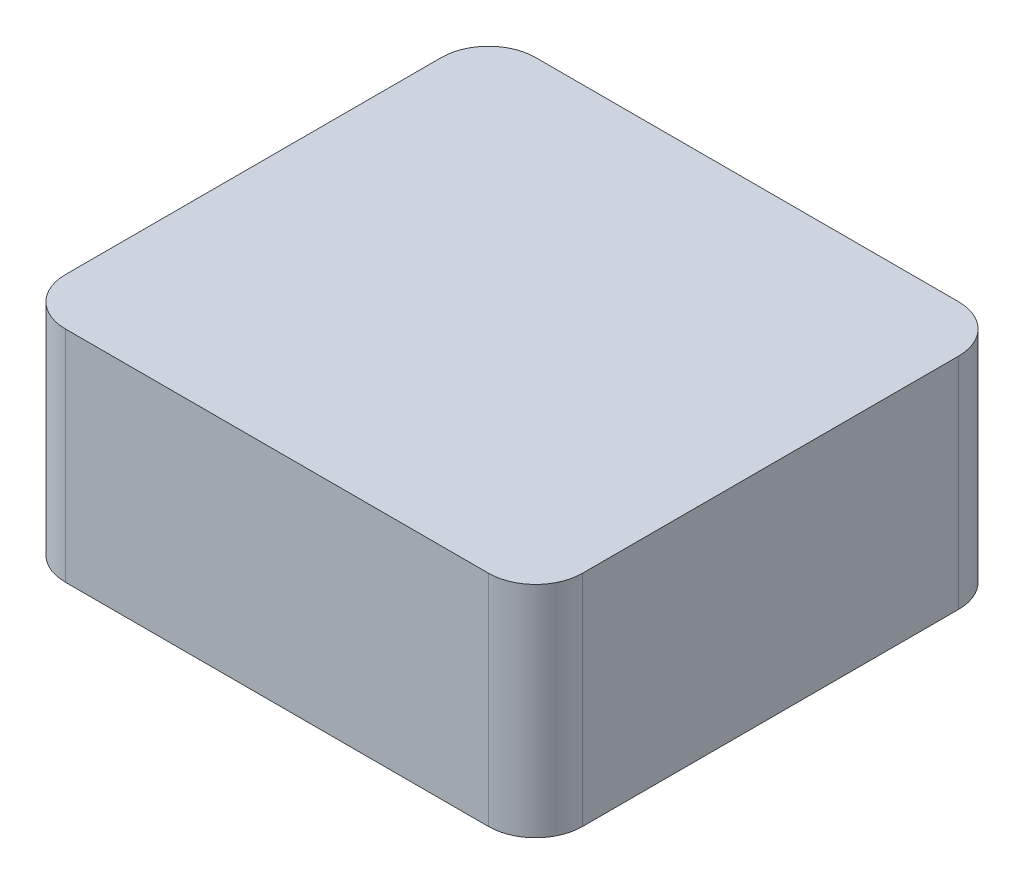
from build123d import *

# Parameters (mm, degrees)
BOSS_EXTRU_1_DEPTH      = 7
BOSS_EXTRU_1_DEPTH_BACK = 7
ESQUISSE1_W             = 33
ESQUISSE1_H             = 30
CONG_1_R                = 3


with BuildPart() as part:
    # Esquisse1 → Boss.-Extru.1 (new, two sides: drawn at the far end of the back side and taken through both)
    with BuildSketch(Plane(origin=(0, 0, 0), x_dir=(1, 0, 0), z_dir=(0, 1, 0)).offset(-BOSS_EXTRU_1_DEPTH_BACK)):
        Rectangle(ESQUISSE1_W, ESQUISSE1_H)
    extrude(amount=BOSS_EXTRU_1_DEPTH + BOSS_EXTRU_1_DEPTH_BACK)

    # Congé1
    cong_1_edges = [part.edges().sort_by_distance(p)[0] for p in [
        (-16.5, 0, -15),
        (16.5, 0, -15),
        (16.5, 0, 15),
        (-16.5, 0, 15),
    ]]
    fillet(cong_1_edges, radius=CONG_1_R)


solid = part.part
